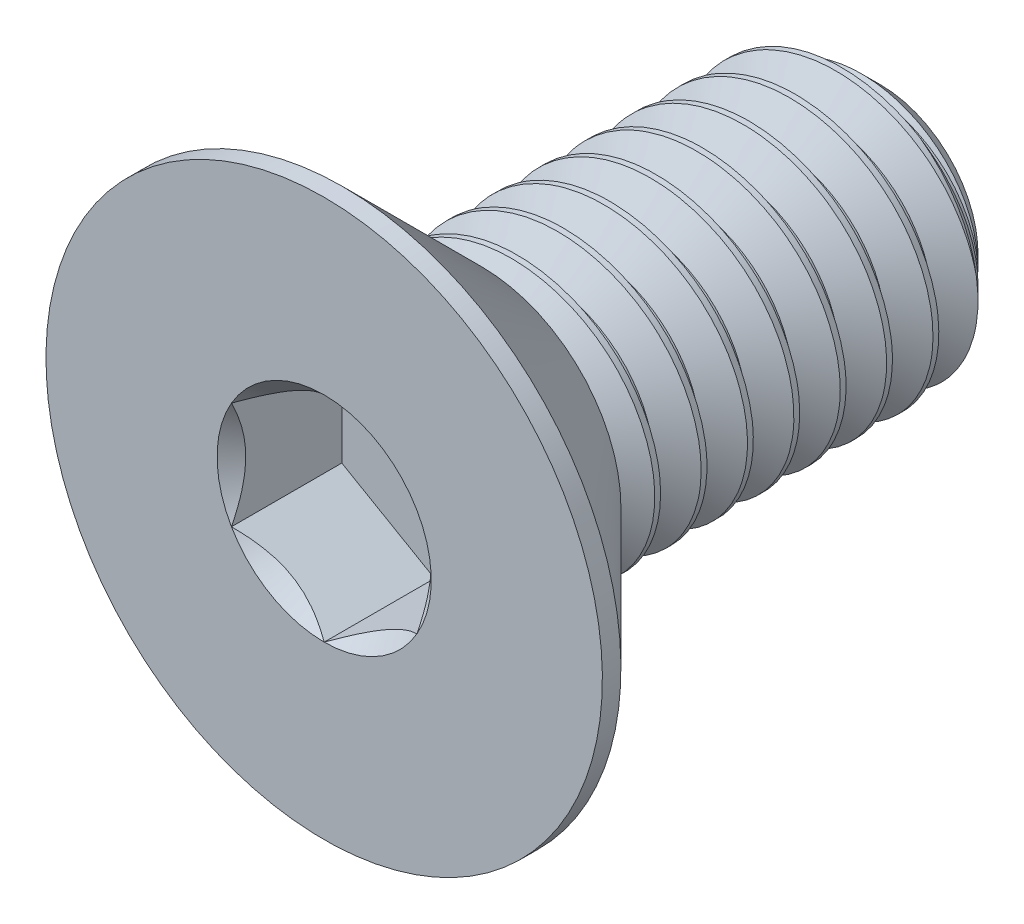
from build123d import *

# Parameters (mm, degrees)
SKETCH3_W              = 6
SKETCH3_H              = 1.5
CHAMFER1_SIZE          = 0.45
CUT_EXTRUDE1_DEPTH     = 1.19
CUT_SWEEP1_PITCH       = 0.5
CUT_SWEEP1_HEIGHT      = 4.8
CUT_SWEEP1_RADIUS      = 1.5
CUT_SWEEP1_START_ANGLE = 90


with BuildPart() as part:
    # Sketch3 → Revolve1 (revolve)
    with BuildSketch(Plane(origin=(0, 0, 0), x_dir=(0, 0, -1), z_dir=(1, 0, 0))):
        with Locations((0, 0.75)):
            Rectangle(SKETCH3_W, SKETCH3_H)
    revolve(axis=Axis((0, 0, -3), (0, 0, 1)))

    # Chamfer1
    chamfer1_edges = [part.edges().sort_by_distance(p)[0] for p in [
        (0, -1.5, -3),
    ]]
    chamfer(chamfer1_edges, length=CHAMFER1_SIZE)

    # Sketch6 → Revolve2 (revolve)
    with BuildSketch(Plane(origin=(0, 0, 0), x_dir=(0, 0, -1), z_dir=(1, 0, 0))):
        Polygon((-3, 3), (-2.8, 3), (-1.3, 1.5), (-1.3, 0), (-3, 0), align=None)
    revolve(axis=Axis((0, 0, -3), (0, 0, 1)))

    # Sketch8 → Cut-Extrude1 (cut)
    with BuildSketch(Plane.XY.offset(3)):
        Polygon((0, 1.154701), (-1, 0.57735), (-1, -0.57735), (0, -1.154701), (1, -0.57735), (1, 0.57735), align=None)
    extrude(amount=-CUT_EXTRUDE1_DEPTH, mode=Mode.SUBTRACT)

    # Cut-Extrude2 cone 1 section (through the dimple's axis) → Cut-Extrude2 (revolve, cut)
    with BuildSketch(Plane(origin=(0, 0, 3), x_dir=(0, -1, 0), z_dir=(1, 0, 0))):
        Polygon((0, 0), (1.154701, 0), (0, 1.154701), align=None)
    revolve(axis=Axis((0, 0, 3), (0, 0, -1)), mode=Mode.SUBTRACT)


with BuildPart() as body_2:
    # Split1: the piece on the far side of the plane
    add(part.part)
    split(bisect_by=Plane.XY.offset(1.3), keep=Keep.BOTTOM)

    # Cut-Sweep1: sweep along a helix
    with BuildLine() as cut_sweep1_path:
        add(Helix(CUT_SWEEP1_PITCH, CUT_SWEEP1_HEIGHT, CUT_SWEEP1_RADIUS, center=(0, 0, -3), direction=(0, 0, 1), mode=Mode.PRIVATE).rotate(Axis((0, 0, -3), (0, 0, 1)), CUT_SWEEP1_START_ANGLE))
    # Sketch10 → Cut-Sweep1 (sweep, cut)
    with BuildSketch(Plane(origin=(0, 0, 0), x_dir=(0, 0, -1), z_dir=(1, 0, 0))):
        Polygon((2.984375, 1.527063), (3.453125, 1.527063), (3.25, 1.17524), (3.1875, 1.17524), align=None)
    sweep(path=cut_sweep1_path.line, is_frenet=True, mode=Mode.SUBTRACT)


with BuildPart() as part_1:
    add(part.part)

    # Split1
    split(bisect_by=Plane.XY.offset(1.3), keep=Keep.TOP)


solid = Compound([body_2.part, part_1.part])
